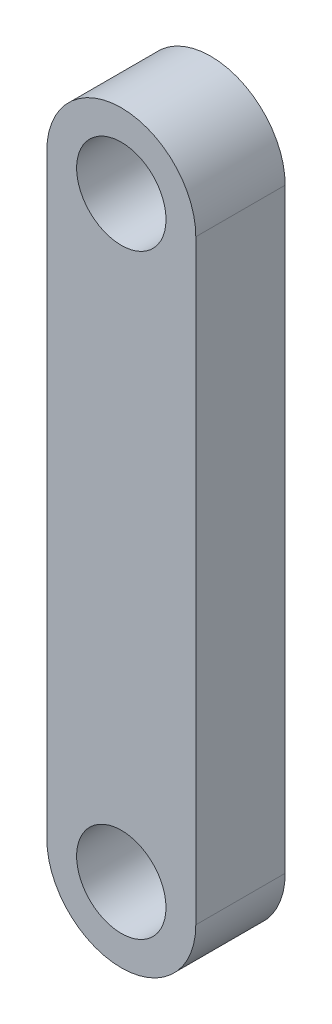
from build123d import *

# Parameters (mm, degrees)
SKETCH1_R           = 7.5
BOSS_EXTRUDE1_DEPTH = 15


with BuildPart() as part:
    # Sketch1 → Boss-Extrude1 (new body)
    with BuildSketch(Plane.XY):
        with BuildLine():
            Line((-12.5, -50), (-12.5, 50))
            ThreePointArc((-12.5, 50), (0, 62.5), (12.5, 50))
            Line((12.5, 50), (12.5, -50))
            ThreePointArc((12.5, -50), (0, -62.5), (-12.5, -50))
        make_face()
        with Locations((0, 50)):
            Circle(SKETCH1_R, mode=Mode.SUBTRACT)
        with Locations((0, -50)):
            Circle(SKETCH1_R, mode=Mode.SUBTRACT)
    extrude(amount=BOSS_EXTRUDE1_DEPTH)


solid = part.part
